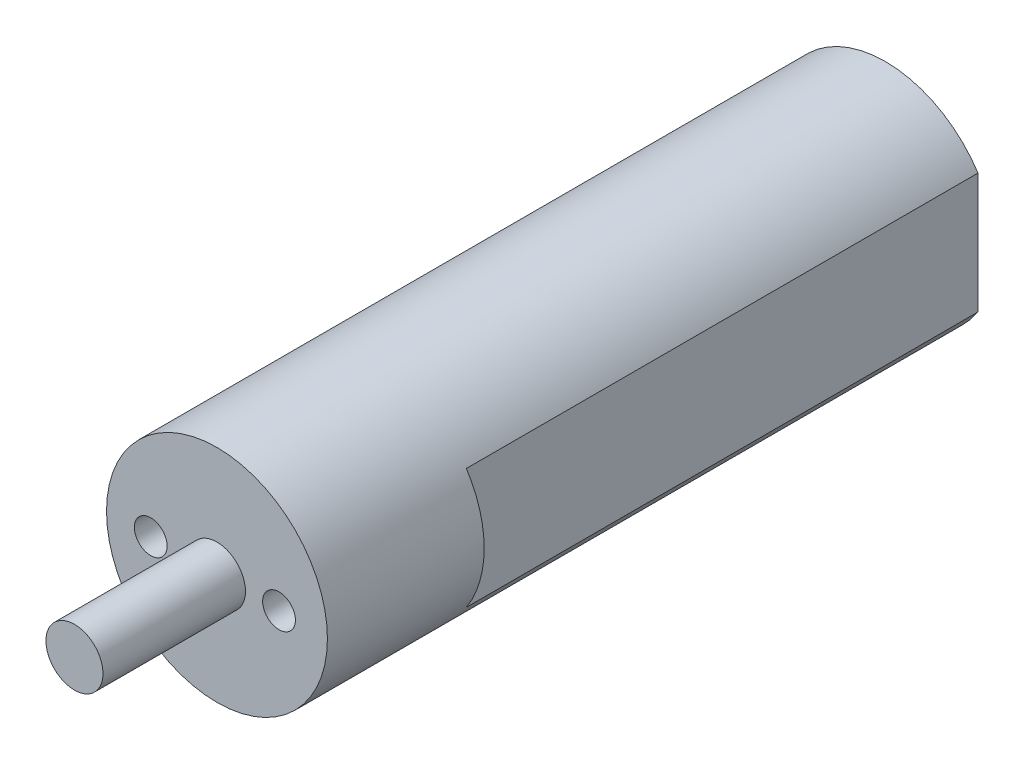
from build123d import *

# Parameters (mm, degrees)
SKETCH_1_R      = 7.75
SKETCH_1_R_2    = 1.15
EXTRUDE_1_DEPTH = 11
EXTRUDE_2_DEPTH = 35.9
SKETCH_3_R      = 2
EXTRUDE_3_DEPTH = 10


with BuildPart() as part:
    # 草图1 → 凸台-拉伸1 (new body)
    with BuildSketch(Plane.XY):
        Circle(SKETCH_1_R)
        with Locations((4.353856496, 0)):
            Circle(SKETCH_1_R_2, mode=Mode.SUBTRACT)
        with Locations((-4.646143504, 0)):
            Circle(SKETCH_1_R_2, mode=Mode.SUBTRACT)
    extrude(amount=-EXTRUDE_1_DEPTH)

    # 草图2 → 凸台-拉伸2 (add)
    with BuildSketch(Plane(origin=(0, 0, -11), x_dir=(-1, 0, 0), z_dir=(0, 0, -1))):
        with BuildLine():
            Line((6.5, 4.220485754), (6.5, -4.220485754))
            ThreePointArc((6.5, -4.220485754), (0, -7.75), (-6.5, -4.220485754))
            Line((-6.5, -4.220485754), (-6.5, 4.220485754))
            ThreePointArc((-6.5, 4.220485754), (0, 7.75), (6.5, 4.220485754))
        make_face()
    extrude(amount=EXTRUDE_2_DEPTH)

    # 草图3 → 凸台-拉伸3 (add)
    with BuildSketch(Plane.XY):
        Circle(SKETCH_3_R)
    extrude(amount=EXTRUDE_3_DEPTH)


solid = part.part
